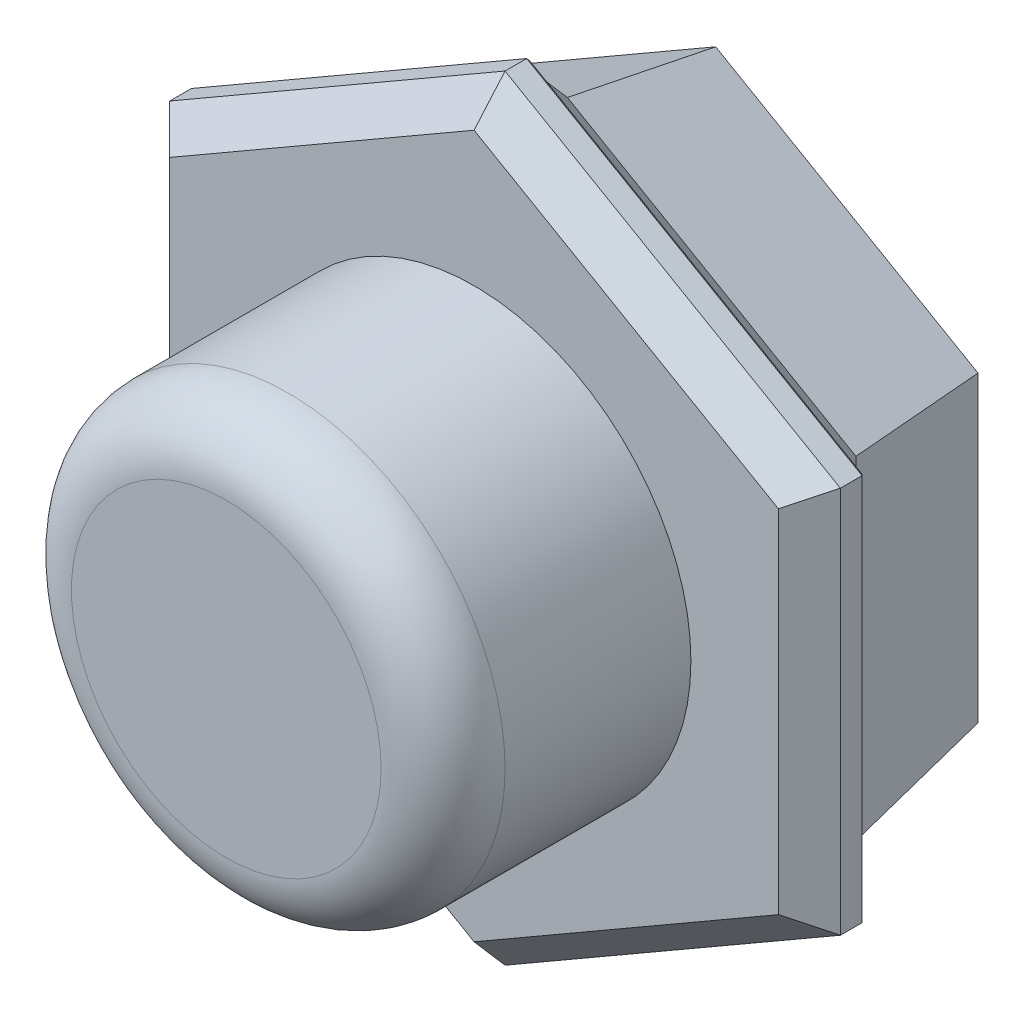
from build123d import *

# Parameters (mm, degrees)
BOSS_EXTRUDE1_DEPTH   = 0.9
CHAMFER1_SIZE         = 0.5
SKETCH5_R             = 3.5
BOSS_EXTRUDE5_DEPTH   = 4
FILLET2_R             = 1
BOSS_EXTRUDE6_DEPTH   = 3
BOSS_EXTRUDE6_TAPER   = 10
CHAMFER2_SIZE2        = 0.616401526
CHAMFER2_SIZE         = 0.5
CHAMFER2_EDGE_2_SIZE2 = 0.616401526
CHAMFER2_EDGE_2_SIZE  = 0.5
CHAMFER2_EDGE_3_SIZE2 = 0.616401526
CHAMFER2_EDGE_3_SIZE  = 0.5
CHAMFER2_EDGE_4_SIZE2 = 0.616401526
CHAMFER2_EDGE_4_SIZE  = 0.5
CHAMFER2_EDGE_5_SIZE2 = 0.616401526
CHAMFER2_EDGE_5_SIZE  = 0.5
CHAMFER2_EDGE_6_SIZE2 = 0.616401526
CHAMFER2_EDGE_6_SIZE  = 0.5
CUT_EXTRUDE1_DEPTH    = 0.5
CUT_EXTRUDE2_DEPTH    = 0.5
CHAMFER3_SIZE         = 0.05


with BuildPart() as part:
    # Sketch1 → Boss-Extrude1 (new body)
    with BuildSketch(Plane.XY):
        Polygon((0, 6.25), (-5.412658774, 3.125), (-5.412658774, -3.125), (0, -6.25), (5.412658774, -3.125), (5.412658774, 3.125), align=None)
    extrude(amount=BOSS_EXTRUDE1_DEPTH)

    # Chamfer1
    chamfer1_edges = [part.edges().sort_by_distance(p)[0] for p in [
        (-5.412658774, 0, 0.9),
        (-2.706329387, -4.6875, 0.9),
        (2.706329387, -4.6875, 0.9),
        (5.412658774, 0, 0.9),
        (2.706329387, 4.6875, 0.9),
        (-2.706329387, 4.6875, 0.9),
    ]]
    chamfer(chamfer1_edges, length=CHAMFER1_SIZE)

    # Sketch5 → Boss-Extrude5 (add)
    with BuildSketch(Plane.XY.offset(0.9)):
        Circle(SKETCH5_R)
    extrude(amount=BOSS_EXTRUDE5_DEPTH)

    # Fillet2
    fillet2_edges = [part.edges().sort_by_distance(p)[0] for p in [
        (-3.5, 0, 4.9),
    ]]
    fillet(fillet2_edges, radius=FILLET2_R)

    # Sketch6 → Boss-Extrude6 (add)
    with BuildSketch(Plane(origin=(0, 0, 0), x_dir=(-1, 0, 0), z_dir=(0, 0, -1))):
        Polygon((0, 5.5), (-4.763139721, 2.75), (-4.763139721, -2.75), (0, -5.5), (4.763139721, -2.75), (4.763139721, 2.75), align=None)
    extrude(amount=BOSS_EXTRUDE6_DEPTH, taper=BOSS_EXTRUDE6_TAPER)

    # Chamfer2
    chamfer2_edges = [part.edges().sort_by_distance(p)[0] for p in [
        (-2.38156986, 4.125, 0),
    ]]
    chamfer(chamfer2_edges, length=CHAMFER2_SIZE, length2=CHAMFER2_SIZE2)

    # Chamfer2 edge 2
    chamfer2_edge_2_edges = [part.edges().sort_by_distance(p)[0] for p in [
        (2.38156986, 4.125, 0),
    ]]
    chamfer(chamfer2_edge_2_edges, length=CHAMFER2_EDGE_2_SIZE, length2=CHAMFER2_EDGE_2_SIZE2)

    # Chamfer2 edge 3
    chamfer2_edge_3_edges = [part.edges().sort_by_distance(p)[0] for p in [
        (4.763139721, 0, 0),
    ]]
    chamfer(chamfer2_edge_3_edges, length=CHAMFER2_EDGE_3_SIZE, length2=CHAMFER2_EDGE_3_SIZE2)

    # Chamfer2 edge 4
    chamfer2_edge_4_edges = [part.edges().sort_by_distance(p)[0] for p in [
        (2.38156986, -4.125, 0),
    ]]
    chamfer(chamfer2_edge_4_edges, length=CHAMFER2_EDGE_4_SIZE, length2=CHAMFER2_EDGE_4_SIZE2)

    # Chamfer2 edge 5
    chamfer2_edge_5_edges = [part.edges().sort_by_distance(p)[0] for p in [
        (-2.38156986, -4.125, 0),
    ]]
    chamfer(chamfer2_edge_5_edges, length=CHAMFER2_EDGE_5_SIZE, length2=CHAMFER2_EDGE_5_SIZE2)

    # Chamfer2 edge 6
    chamfer2_edge_6_edges = [part.edges().sort_by_distance(p)[0] for p in [
        (-4.763139721, 0, 0),
    ]]
    chamfer(chamfer2_edge_6_edges, length=CHAMFER2_EDGE_6_SIZE, length2=CHAMFER2_EDGE_6_SIZE2)

    # Sketch7 → Cut-Extrude1 (cut)
    with BuildSketch(Plane(origin=(0, 0, -3), x_dir=(-1, 0, 0), z_dir=(0, 0, -1))):
        Polygon((2.421562936, -1.714378483), (1.358271796, -1.714378483), (1.358271796, -3.663745572), (0.472195847, -3.663745572), (0.472195847, -1.714378483), (-2.894892761, -1.714378483), (-2.894892761, -0.628935446), (0.509577176, 3.336254428), (1.358271796, 3.336254428), (1.358271796, -0.916910129), (2.421562936, -0.916910129), align=None)
        Polygon((0.472195847, -0.916910129), (0.472195847, 2.205123099), (-2.2081839, -0.916910129), align=None, mode=Mode.SUBTRACT)
    extrude(amount=-CUT_EXTRUDE1_DEPTH, mode=Mode.SUBTRACT)

    # Sketch8 → Cut-Extrude2 (cut)
    with BuildSketch(Plane(origin=(0, 0, -3), x_dir=(-1, 0, 0), z_dir=(0, 0, -1))):
        Polygon((0.472195847, 2.205123099), (-2.2081839, -0.916910129), (0.472195847, -0.916910129), align=None)
    extrude(amount=-CUT_EXTRUDE2_DEPTH, mode=Mode.SUBTRACT)

    # Chamfer3
    chamfer3_edges = [part.edges().sort_by_distance(p)[0] for p in [
        (5.412658774, 0, 0),
        (2.706329387, -4.6875, 0),
        (-2.706329387, -4.6875, 0),
        (-5.412658774, 0, 0),
        (-2.706329387, 4.6875, 0),
        (2.706329387, 4.6875, 0),
    ]]
    chamfer(chamfer3_edges, length=CHAMFER3_SIZE)


solid = part.part
